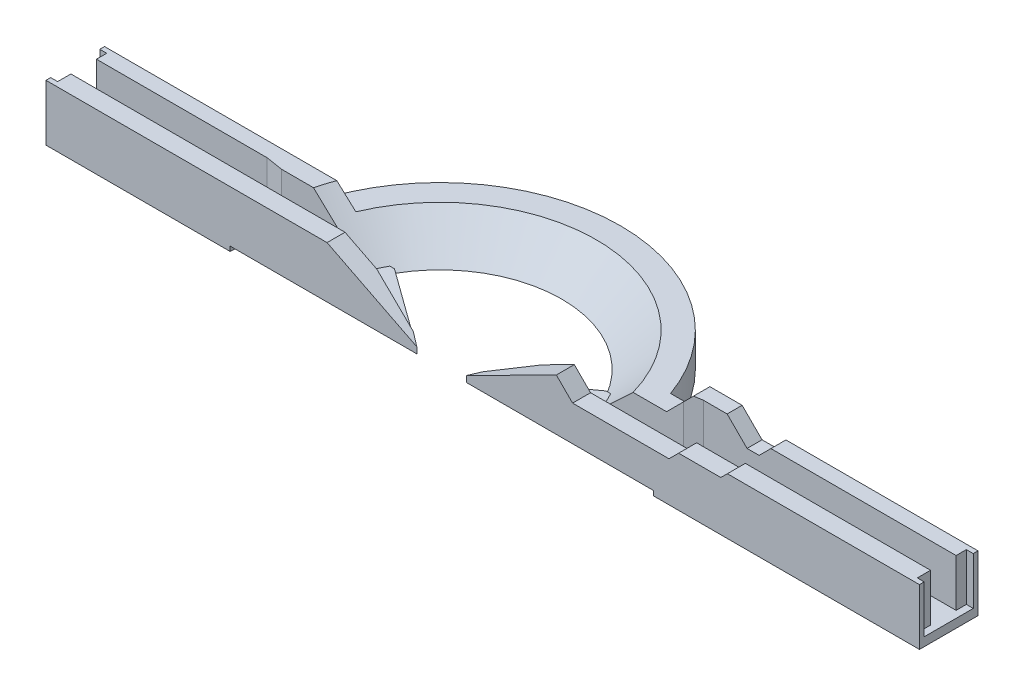
from build123d import *

# Parameters (mm, degrees)
BOSS_EXTRUDE4_DEPTH   = 41.275
BOSS_EXTRUDE4_2_DEPTH = 41.275
BOSS_EXTRUDE4_3_DEPTH = 41.275
BOSS_EXTRUDE4_4_DEPTH = 41.275
CUT_EXTRUDE12_DEPTH   = 10.668
CUT_EXTRUDE13_DEPTH   = 29.972
CUT_EXTRUDE7_DEPTH    = 44.0276
CUT_EXTRUDE9_DEPTH    = 15.24
BOSS_EXTRUDE6_DEPTH   = 5.969
CUT_EXTRUDE15_DEPTH   = 19.05
REVOLVE1_ANGLE        = 142
CUT_REVOLVE1_ANGLE    = 153
SKETCH39_W            = 642.112
SKETCH39_H            = 43.0276
BOSS_EXTRUDE5_DEPTH   = 6.35
SKETCH38_R            = 155.575
CUT_EXTRUDE14_DEPTH   = 3.429
CUT_EXTRUDE16_DEPTH   = 48.244


with BuildPart() as part:
    # Sketch5 → Boss-Extrude4 (new body)
    with BuildSketch(Plane(origin=(0, 88.9762, 0), x_dir=(1, 0, 0), z_dir=(0, 1, 0))):
        Polygon((281.7495, 153.8224), (9.144, 153.8224), (9.144, 157.3022), (14.224, 157.3022), (14.224, 167.0304), (261.323220327, 167.0304), align=None)
    extrude(amount=BOSS_EXTRUDE4_DEPTH)


with BuildPart() as body_2:
    # Sketch5 → Boss-Extrude4 2 (new body)
    with BuildSketch(Plane(origin=(0, 88.9762, 0), x_dir=(1, 0, 0), z_dir=(0, 1, 0))):
        with BuildLine():
            Line((9.144, 196.85), (230.476735197, 196.85))
            ThreePointArc((230.476735197, 196.85), (228.329031076, 193.294962827), (226.362857042, 189.6364))
            Line((226.362857042, 189.6364), (235.397557666, 183.7944))
            Line((235.397557666, 183.7944), (152.4, 183.7944))
            Line((152.4, 183.7944), (139.7, 185.8264))
            Line((139.7, 185.8264), (14.224, 185.8264))
            Line((14.224, 185.8264), (14.224, 193.3702))
            Line((14.224, 193.3702), (9.144, 193.3702))
            Line((9.144, 193.3702), (9.144, 196.85))
        make_face()
    extrude(amount=BOSS_EXTRUDE4_2_DEPTH)


with BuildPart() as body_3:
    # Sketch5 → Boss-Extrude4 3 (new body)
    with BuildSketch(Plane(origin=(0, 88.9762, 0), x_dir=(1, 0, 0), z_dir=(0, 1, 0))):
        with BuildLine():
            Line((364.677442334, 183.7944), (373.712142958, 189.6364))
            ThreePointArc((373.712142958, 189.6364), (371.745968924, 193.294962827), (369.598264803, 196.85))
            Line((369.598264803, 196.85), (651.256, 196.85))
            Line((651.256, 196.85), (651.256, 193.3702))
            Line((651.256, 193.3702), (646.176, 193.3702))
            Line((646.176, 193.3702), (646.176, 185.8264))
            Line((646.176, 185.8264), (460.375, 185.8264))
            Line((460.375, 185.8264), (447.675, 183.7944))
            Line((447.675, 183.7944), (364.677442334, 183.7944))
        make_face()
    extrude(amount=BOSS_EXTRUDE4_3_DEPTH)


with BuildPart() as body_4:
    # Sketch5 → Boss-Extrude4 4 (new body)
    with BuildSketch(Plane(origin=(0, 88.9762, 0), x_dir=(1, 0, 0), z_dir=(0, 1, 0))):
        Polygon((646.176, 167.0304), (338.751779673, 167.0304), (318.3255, 153.8224), (651.256, 153.8224), (651.256, 157.3022), (646.176, 157.3022), align=None)
    extrude(amount=BOSS_EXTRUDE4_4_DEPTH)


with BuildPart() as cut_extrude12_tool:
    # Sketch22_2 → Cut-Extrude12 (new body)
    with BuildSketch(Plane.XY.offset(-153.8224)):
        Polygon((318.3255, 96.926341572), (384.316635768, 130.2512), (215.758364232, 130.2512), (281.7495, 96.926341572), (281.7495, 92.1512), (318.3255, 92.1512), align=None)
    extrude(amount=-CUT_EXTRUDE12_DEPTH)


with BuildPart() as part_1:
    add(part.part)

    # Cut-Extrude12: cut by cut_extrude12_tool
    add(cut_extrude12_tool.part, mode=Mode.SUBTRACT)


with BuildPart() as body_4_1:
    add(body_4.part)

    # Cut-Extrude12: cut by cut_extrude12_tool
    add(cut_extrude12_tool.part, mode=Mode.SUBTRACT)


with BuildPart() as cut_extrude13_tool:
    # Sketch22_3 → Cut-Extrude13 (new body)
    with BuildSketch(Plane.XY.offset(-153.8224)):
        Polygon((318.3255, 96.926341572), (384.316635768, 130.2512), (215.758364232, 130.2512), (281.7495, 96.926341572), (281.7495, 92.1512), (318.3255, 92.1512), align=None)
    extrude(amount=-CUT_EXTRUDE13_DEPTH)


with BuildPart() as part_2:
    add(part_1.part)

    # Cut-Extrude13: cut by cut_extrude13_tool
    add(cut_extrude13_tool.part, mode=Mode.SUBTRACT)


with BuildPart() as body_4_2:
    add(body_4_1.part)

    # Cut-Extrude13: cut by cut_extrude13_tool
    add(cut_extrude13_tool.part, mode=Mode.SUBTRACT)

    # Sketch26 → Cut-Extrude9 (cut)
    with BuildSketch(Plane.XY.offset(-153.8224)):
        Polygon((510.032, 130.2512), (505.206, 125.4252), (474.218, 125.4252), (467.106, 118.3132), (396.254635768, 118.3132), (384.316635768, 130.2512), align=None)
    extrude(amount=-CUT_EXTRUDE9_DEPTH, mode=Mode.SUBTRACT)


with BuildPart() as cut_extrude7_tool:
    # Sketch22 → Cut-Extrude7 (new body, through all)
    with BuildSketch(Plane.XY.offset(-153.8224)):
        Polygon((318.3255, 96.926341572), (384.316635768, 130.2512), (215.758364232, 130.2512), (281.7495, 96.926341572), (281.7495, 92.1512), (318.3255, 92.1512), align=None)
    extrude(amount=-CUT_EXTRUDE7_DEPTH)


with BuildPart() as body_2_1:
    add(body_2.part)

    # Cut-Extrude7: cut by cut_extrude7_tool
    add(cut_extrude7_tool.part, mode=Mode.SUBTRACT)



with BuildPart() as body_3_1:
    add(body_3.part)

    # Cut-Extrude7: cut by cut_extrude7_tool
    add(cut_extrude7_tool.part, mode=Mode.SUBTRACT)

    # Sketch42 → Boss-Extrude6 (add)
    with BuildSketch(Plane(origin=(0, 130.2512, 0), x_dir=(1, 0, 0), z_dir=(0, 1, 0))):
        Polygon((396.254635768, 196.85), (510.032, 196.85), (510.032, 185.8264), (460.375, 185.8264), (447.675, 183.7944), (396.254635768, 183.7944), align=None)
    extrude(amount=BOSS_EXTRUDE6_DEPTH)

    # Sketch36 → Cut-Extrude15 (cut)
    with BuildSketch(Plane.XY.offset(-196.85)):
        Polygon((435.356, 117.4242), (454.2028, 136.271), (477.819866452, 136.271), (492.506, 121.584866452), (501.365666452, 121.584866452), (510.032, 130.2512), (531.547497997, 151.766697997), (332.480700093, 151.766697997), (332.480700093, 117.4242), align=None)
    extrude(amount=CUT_EXTRUDE15_DEPTH, mode=Mode.SUBTRACT)


with BuildPart() as body_2_2:
    add(body_2_1.part)

    add(body_3_1.part)  # Revolve1 merges body 3
    # Sketch37 → Revolve1 (revolve, symmetric)
    with BuildSketch(Plane(origin=(300.0502, 0, 0), x_dir=(0, 0, -1), z_dir=(1, 0, 0))) as revolve1_sk:
        Polygon((238.506, 88.9762), (285.242, 88.9762), (285.242, 117.4242), (267.462, 117.4242), align=None)
    revolve(axis=Axis((300.0502, 133.091662173, -152.4), (0, -1, 0)), revolution_arc=REVOLVE1_ANGLE / 2)
    revolve(revolve1_sk.sketch, axis=Axis((300.0502, 133.091662173, -152.4), (0, 1, 0)), revolution_arc=REVOLVE1_ANGLE / 2)


with BuildPart() as cut_revolve1_tool:
    # Sketch41 → Cut-Revolve1 (revolve, symmetric)
    with BuildSketch(Plane(origin=(300.0502, 0, 0), x_dir=(0, 0, -1), z_dir=(1, 0, 0))) as cut_revolve1_sk:
        Polygon((290.213142857, 139.7762), (238.506, 88.9762), (171.45, 88.9762), (171.45, 139.7762), align=None)
    revolve(axis=Axis((300.0502, 150.973417034, -152.4), (0, -1, 0)), revolution_arc=CUT_REVOLVE1_ANGLE / 2)
    revolve(cut_revolve1_sk.sketch, axis=Axis((300.0502, 150.973417034, -152.4), (0, 1, 0)), revolution_arc=CUT_REVOLVE1_ANGLE / 2)


with BuildPart() as part_3:
    add(part_2.part)

    # Cut-Revolve1: cut by cut_revolve1_tool
    add(cut_revolve1_tool.part, mode=Mode.SUBTRACT)



with BuildPart() as body_2_3:
    add(body_2_2.part)

    # Cut-Revolve1: cut by cut_revolve1_tool
    add(cut_revolve1_tool.part, mode=Mode.SUBTRACT)


with BuildPart() as body_4_3:
    add(body_4_2.part)

    # Cut-Revolve1: cut by cut_revolve1_tool
    add(cut_revolve1_tool.part, mode=Mode.SUBTRACT)


with BuildPart() as part_4:
    add(part_3.part)

    add(body_2_3.part)  # Boss-Extrude5 merges body 2

    add(body_4_3.part)  # Boss-Extrude5 merges body 4
    # Sketch39 → Boss-Extrude5 (add)
    with BuildSketch(Plane.XZ.offset(-88.9762)):
        with Locations((330.2, -175.3362)):
            Rectangle(SKETCH39_W, SKETCH39_H)
    extrude(amount=-BOSS_EXTRUDE5_DEPTH)

    # Sketch38 → Cut-Extrude14 (cut)
    with BuildSketch(Plane.XZ.offset(-88.9762)):
        with Locations((300.0502, -152.4)):
            Circle(SKETCH38_R)
    extrude(amount=-CUT_EXTRUDE14_DEPTH, mode=Mode.SUBTRACT)

    # Sketch43 → Cut-Extrude16 (cut, through all)
    with BuildSketch(Plane(origin=(0, 136.2202, 0), x_dir=(1, 0, 0), z_dir=(0, 1, 0))):
        with BuildLine():
            Line((281.7495, 153.8224), (222.257640496, 196.85))
            ThreePointArc((222.257640496, 196.85), (300.0502, 241.996232143), (377.842759504, 196.85))
            Line((377.842759504, 196.85), (318.3255, 153.8224))
            Line((318.3255, 153.8224), (281.7495, 153.8224))
        make_face()
    extrude(amount=-CUT_EXTRUDE16_DEPTH, mode=Mode.SUBTRACT)


solid = part_4.part
